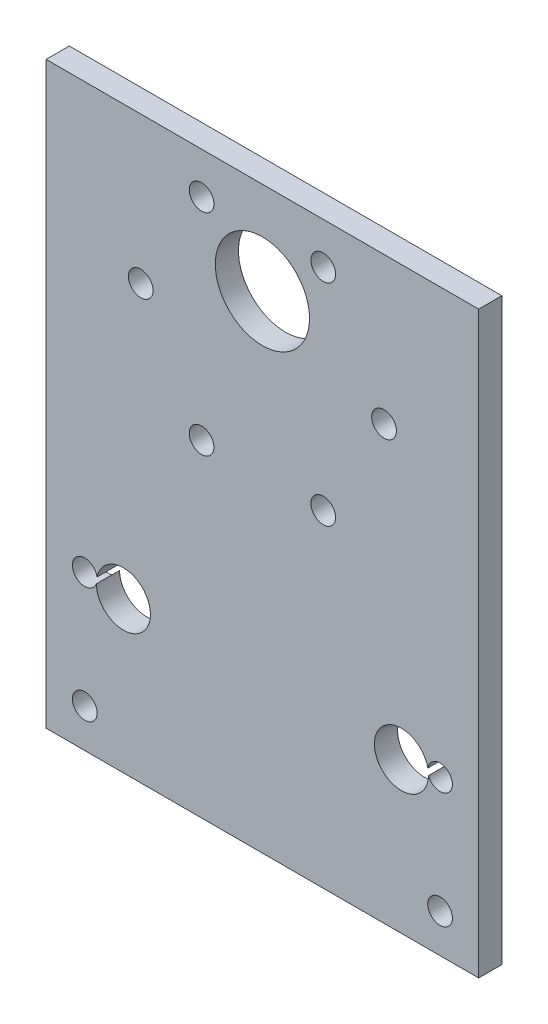
from build123d import *

# Parameters (mm, degrees)
SKETCH_1_W          = 56
SKETCH_1_H          = 25
SKETCH_1_R          = 3.5
EXTRUDE_1_DEPTH     = 3
CUT_EXTRUDE_1_DEPTH = 4
SKETCH_3_W          = 56
SKETCH_3_H          = 3
EXTRUDE_2_DEPTH     = 50
SKETCH_4_R          = 1.6
SKETCH_4_R_2        = 6.1
CUT_EXTRUDE_4_DEPTH = 40


with BuildPart() as part:
    # ｽｹｯﾁ1 → ﾎﾞｽ - 押し出し1 (new body)
    with BuildSketch(Plane.XY):
        Rectangle(SKETCH_1_W, SKETCH_1_H)
        with Locations((-18, 7)):
            Circle(SKETCH_1_R, mode=Mode.SUBTRACT)
        with Locations((18, 7)):
            Circle(SKETCH_1_R, mode=Mode.SUBTRACT)
    extrude(amount=EXTRUDE_1_DEPTH)

    # ｽｹｯﾁ2 → ｶｯﾄ - 押し出し1 (cut, through all)
    with BuildSketch(Plane.XY.offset(3)):
        with BuildLine():
            ThreePointArc((-21.4, 7.5), (-21.86862915, 8.63137085), (-23, 9.1))
            Line((-23, 9.1), (-23, 7.5))
            Line((-23, 7.5), (-24.6, 7.5))
            ThreePointArc((-24.6, 7.5), (-23, 5.9), (-21.4, 7.5))
        make_face()
        with BuildLine():
            Line((-23, 7.5), (-23, 9.1))
            ThreePointArc((-23, 9.1), (-24.13137085, 8.63137085), (-24.6, 7.5))
            Line((-24.6, 7.5), (-23, 7.5))
        make_face()
        with BuildLine():
            ThreePointArc((-24.6, -7.5), (-24.13137085, -8.63137085), (-23, -9.1))
            Line((-23, -9.1), (-23, -7.5))
            Line((-23, -7.5), (-24.6, -7.5))
        make_face()
        with BuildLine():
            Line((-23, -7.5), (-23, -9.1))
            ThreePointArc((-23, -9.1), (-21.86862915, -8.63137085), (-21.4, -7.5))
            ThreePointArc((-21.4, -7.5), (-23, -5.9), (-24.6, -7.5))
            Line((-24.6, -7.5), (-23, -7.5))
        make_face()
        with BuildLine():
            ThreePointArc((24.6, 7.5), (24.13137085, 8.63137085), (23, 9.1))
            Line((23, 9.1), (23, 7.5))
            Line((23, 7.5), (24.6, 7.5))
        make_face()
        with BuildLine():
            Line((23, 7.5), (23, 9.1))
            ThreePointArc((23, 9.1), (21.86862915, 6.36862915), (24.6, 7.5))
            Line((24.6, 7.5), (23, 7.5))
        make_face()
        with BuildLine():
            ThreePointArc((24.6, -7.5), (21.86862915, -6.36862915), (23, -9.1))
            Line((23, -9.1), (23, -7.5))
            Line((23, -7.5), (24.6, -7.5))
        make_face()
        with BuildLine():
            Line((23, -7.5), (23, -9.1))
            ThreePointArc((23, -9.1), (24.13137085, -8.63137085), (24.6, -7.5))
            Line((24.6, -7.5), (23, -7.5))
        make_face()
    extrude(amount=-CUT_EXTRUDE_1_DEPTH, mode=Mode.SUBTRACT)

    # ｽｹｯﾁ3 → ﾎﾞｽ - 押し出し2 (add)
    with BuildSketch(Plane(origin=(0, 12.5, 0), x_dir=(1, 0, 0), z_dir=(0, 1, 0))):
        with Locations((0, -1.5)):
            Rectangle(SKETCH_3_W, SKETCH_3_H)
    extrude(amount=EXTRUDE_2_DEPTH)

    # ｽｹｯﾁ4 → ｶｯﾄ - 押し出し4 (cut)
    with BuildSketch(Plane.XY):
        with Locations((-7.875, 57.13990011)):
            Circle(SKETCH_4_R)
        with Locations((7.875, 57.13990011)):
            Circle(SKETCH_4_R)
        with Locations((15.75, 43.5)):
            Circle(SKETCH_4_R)
        with Locations((7.875, 29.86009989)):
            Circle(SKETCH_4_R)
        with Locations((-7.875, 29.86009989)):
            Circle(SKETCH_4_R)
        with Locations((-15.75, 43.5)):
            Circle(SKETCH_4_R)
        with Locations((0, 50.5)):
            Circle(SKETCH_4_R_2)
    extrude(amount=CUT_EXTRUDE_4_DEPTH, mode=Mode.SUBTRACT)


solid = part.part
